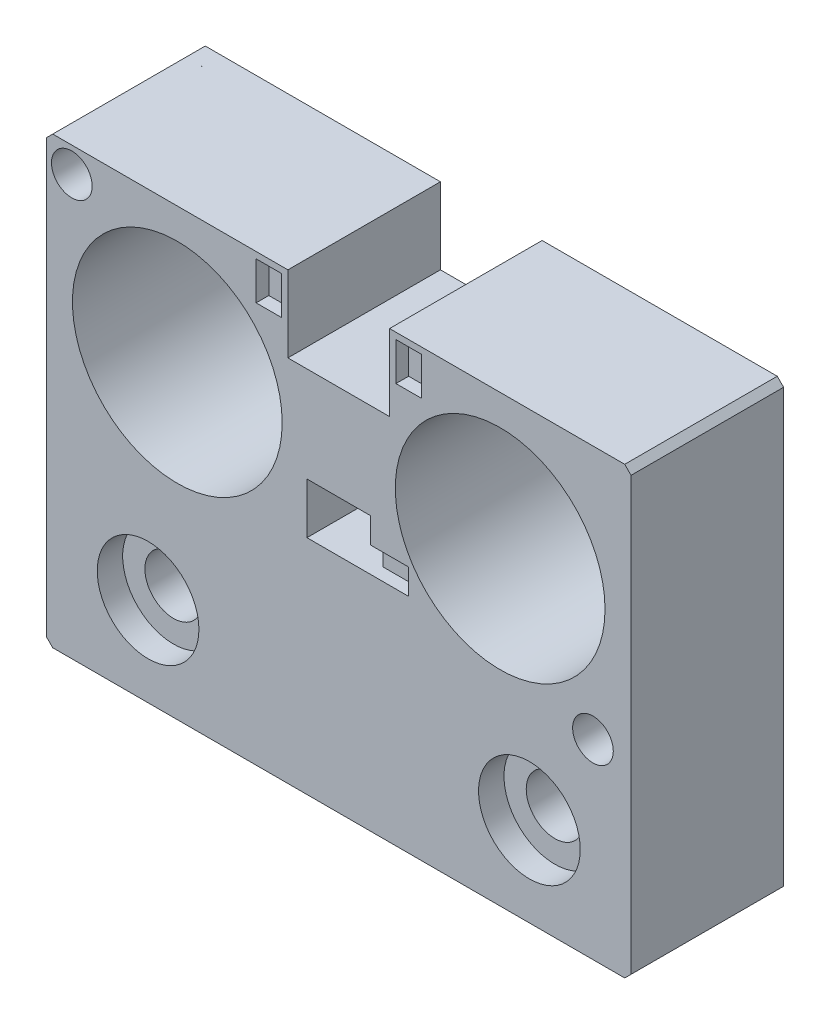
from build123d import *

# Parameters (mm, degrees)
SKETCH_1_W           = 46
SKETCH_1_H           = 20
EXTRUDE_1_DEPTH      = 12
SKETCH_2_R           = 8.25
CUT_EXTRUDE_1_DEPTH  = 13
SKETCH_3_W           = 8
SKETCH_3_H           = 6
CUT_EXTRUDE_2_DEPTH  = 13
SKETCH_4_W           = 5
SKETCH_4_H           = 4
CUT_EXTRUDE_3_DEPTH  = 13
SKETCH_5_W           = 3
SKETCH_5_H           = 2
SKETCH_5_W_2         = 2
SKETCH_5_H_2         = 3
CUT_EXTRUDE_4_DEPTH  = 1
SKETCH_6_W           = 46
SKETCH_6_H           = 12
EXTRUDE_2_DEPTH      = 15
SKETCH_14_R          = 1.6
CUT_EXTRUDE_10_DEPTH = 46
SKETCH_15_R          = 2.25
CUT_EXTRUDE_11_DEPTH = 13
SKETCH1_R            = 1.6
CUT_EXTRUDE1_DEPTH   = 13
SKETCH2_R            = 4
CUT_EXTRUDE2_DEPTH   = 2
CHAMFER1_SIZE        = 0.5
CHAMFER2_SIZE        = 0.5


with BuildPart() as part:
    # 草圖1 → 填料-伸長1 (new body)
    with BuildSketch(Plane.XY):
        Rectangle(SKETCH_1_W, SKETCH_1_H)
    extrude(amount=EXTRUDE_1_DEPTH)

    # 草圖2 → 除料-伸長1 (cut, through all)
    with BuildSketch(Plane.XY.offset(12)):
        with Locations((-12.7, -0.65)):
            Circle(SKETCH_2_R)
        with Locations((12.7, -0.65)):
            Circle(SKETCH_2_R)
    extrude(amount=-CUT_EXTRUDE_1_DEPTH, mode=Mode.SUBTRACT)

    # 草圖3 → 除料-伸長2 (cut, through all)
    with BuildSketch(Plane.XY.offset(12)):
        with Locations((0, 7)):
            Rectangle(SKETCH_3_W, SKETCH_3_H)
    extrude(amount=-CUT_EXTRUDE_2_DEPTH, mode=Mode.SUBTRACT)

    # 草圖4 → 除料-伸長3 (cut, through all)
    with BuildSketch(Plane.XY.offset(12)):
        with Locations((0, -5.5)):
            Rectangle(SKETCH_4_W, SKETCH_4_H)
    extrude(amount=-CUT_EXTRUDE_3_DEPTH, mode=Mode.SUBTRACT)

    # 草圖5 → 除料-伸長4 (cut)
    with BuildSketch(Plane.XY.offset(12)):
        with Locations((4, -6.5)):
            Rectangle(SKETCH_5_W, SKETCH_5_H)
        with Locations((-5.5, 8)):
            Rectangle(SKETCH_5_W_2, SKETCH_5_H_2)
        with Locations((5.5, 8)):
            Rectangle(SKETCH_5_W_2, SKETCH_5_H_2)
    extrude(amount=-CUT_EXTRUDE_4_DEPTH, mode=Mode.SUBTRACT)

    # 草圖6 → 填料-伸長2 (add)
    with BuildSketch(Plane.XZ.offset(10)):
        with Locations((0, 6)):
            Rectangle(SKETCH_6_W, SKETCH_6_H)
    extrude(amount=EXTRUDE_2_DEPTH)

    # 草圖14 → 除料-伸長10 (cut)
    with BuildSketch(Plane.XY.offset(12)):
        with Locations((-21, 8)):
            Circle(SKETCH_14_R)
    extrude(amount=-CUT_EXTRUDE_10_DEPTH, mode=Mode.SUBTRACT)

    # 草圖15 → 除料-伸長11 (cut, through all)
    with BuildSketch(Plane(origin=(0, 0, 0), x_dir=(-1, 0, 0), z_dir=(0, 0, -1))):
        with Locations((-15, -18)):
            Circle(SKETCH_15_R)
        with Locations((15, -18)):
            Circle(SKETCH_15_R)
    extrude(amount=-CUT_EXTRUDE_11_DEPTH, mode=Mode.SUBTRACT)

    # Sketch1 → Cut-Extrude1 (cut, through all)
    with BuildSketch(Plane.XY.offset(12)):
        with Locations((20, -10)):
            Circle(SKETCH1_R)
    extrude(amount=-CUT_EXTRUDE1_DEPTH, mode=Mode.SUBTRACT)

    # Sketch2 → Cut-Extrude2 (cut)
    with BuildSketch(Plane.XY.offset(12)):
        with Locations((-15, -18)):
            Circle(SKETCH2_R)
        with Locations((15, -18)):
            Circle(SKETCH2_R)
    extrude(amount=-CUT_EXTRUDE2_DEPTH, mode=Mode.SUBTRACT)

    # Chamfer1
    chamfer1_edges = [part.edges().sort_by_distance(p)[0] for p in [
        (-23, 10, 6),
        (23, 10, 6),
    ]]
    chamfer(chamfer1_edges, length=CHAMFER1_SIZE)

    # Chamfer2
    chamfer2_edges = [part.edges().sort_by_distance(p)[0] for p in [
        (-23, -25, 6),
        (23, -25, 6),
    ]]
    chamfer(chamfer2_edges, length=CHAMFER2_SIZE)


solid = part.part
